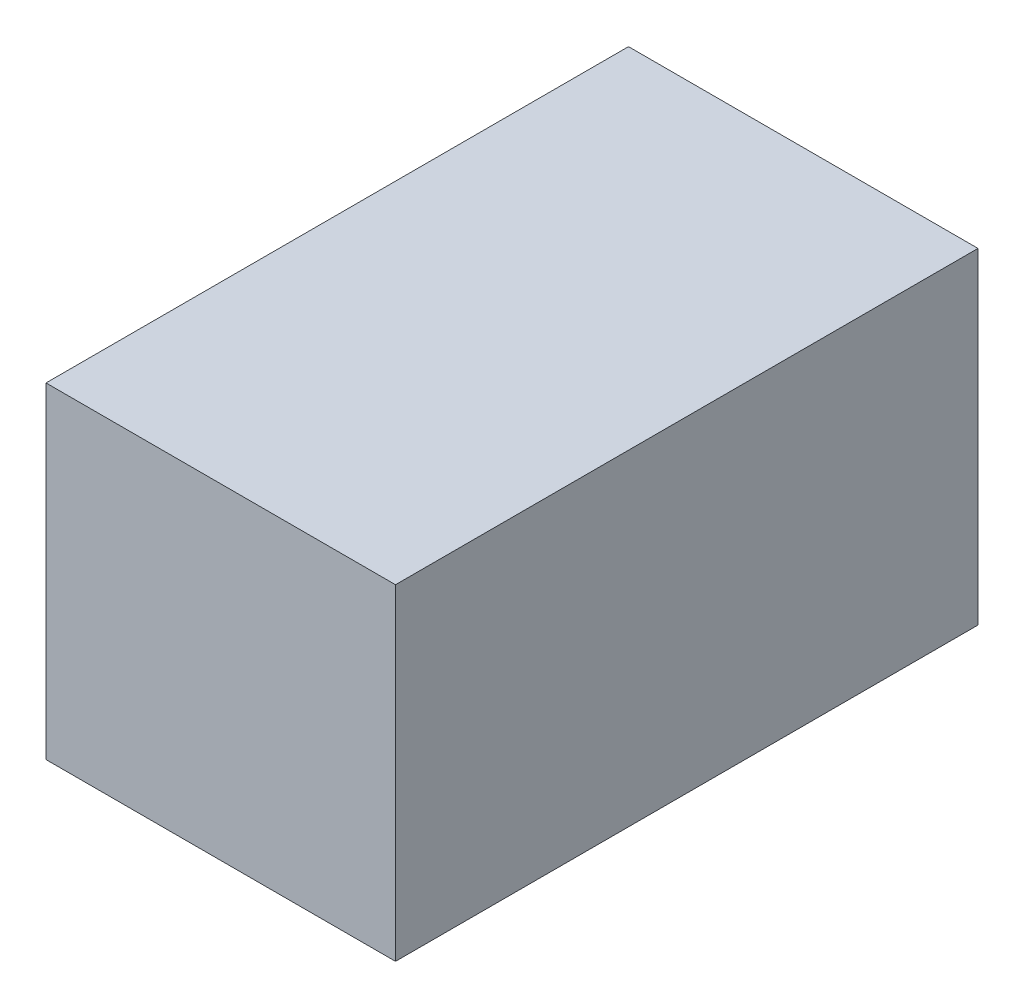
from build123d import *

# Parameters (mm, degrees)
SKETCH1_W           = 3
SKETCH1_H           = 2.8
BOSS_EXTRUDE1_DEPTH = 5


with BuildPart() as part:
    # Sketch1 → Boss-Extrude1 (new body)
    with BuildSketch(Plane.XY):
        with Locations((1.5, -1.4)):
            Rectangle(SKETCH1_W, SKETCH1_H)
    extrude(amount=BOSS_EXTRUDE1_DEPTH)


solid = part.part
